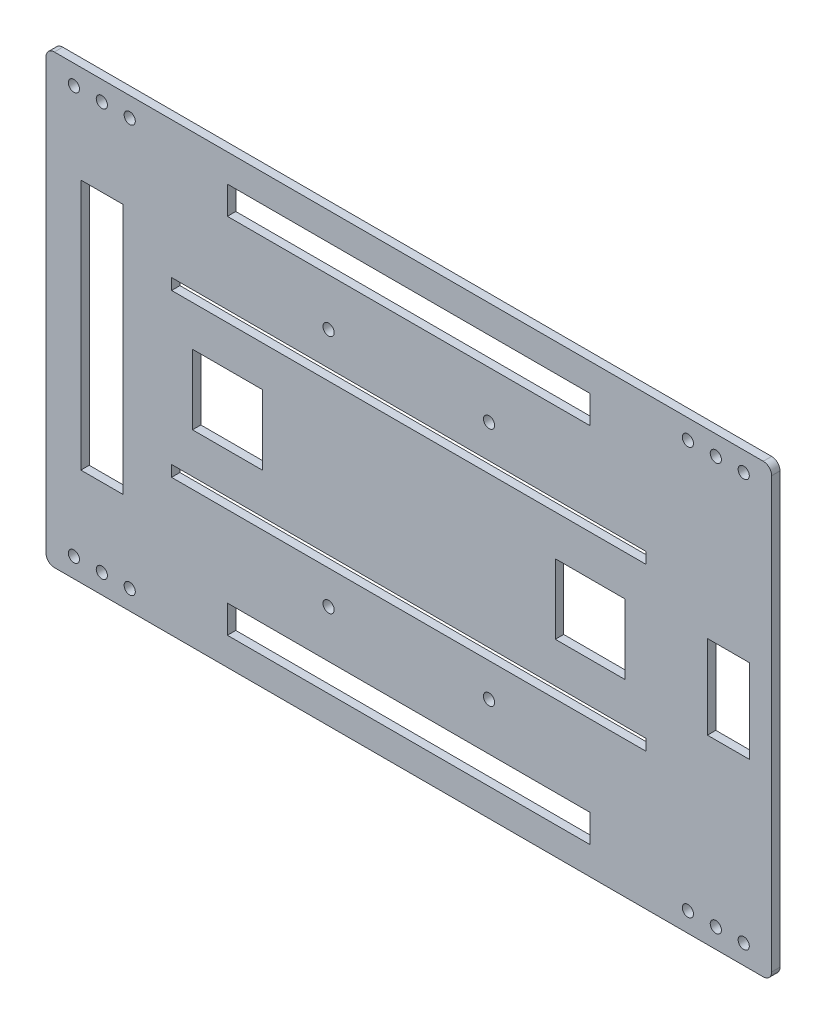
from build123d import *

# Parameters (mm, degrees)
MODEL_R             = 2
MODEL_W             = 130
MODEL_H             = 10
MODEL_W_2           = 15
MODEL_H_2           = 90
MODEL_W_3           = 25
MODEL_H_3           = 25
MODEL_H_4           = 30
MODEL_W_4           = 170
MODEL_H_5           = 4
EXTRUDE_1_DEPTH     = 3
SKETCH_1_R          = 2
CUT_EXTRUDE_1_DEPTH = 10


with BuildPart() as part:
    # Model → 凸台-拉伸1 (new body)
    with BuildSketch(Plane.XY):
        with BuildLine():
            Line((130, -77), (130, 77))
            ThreePointArc((130, 77), (129.121320344, 79.121320344), (127, 80))
            Line((127, 80), (-127, 80))
            ThreePointArc((-127, 80), (-129.121320344, 79.121320344), (-130, 77))
            Line((-130, 77), (-130, -77))
            ThreePointArc((-130, -77), (-129.121320344, -79.121320344), (-127, -80))
            Line((-127, -80), (127, -80))
            ThreePointArc((127, -80), (129.121320344, -79.121320344), (130, -77))
        make_face()
        with Locations((-110, 73)):
            Circle(MODEL_R, mode=Mode.SUBTRACT)
        with Locations((110, 73)):
            Circle(MODEL_R, mode=Mode.SUBTRACT)
        with Locations((110, -73)):
            Circle(MODEL_R, mode=Mode.SUBTRACT)
        with Locations((-110, -73)):
            Circle(MODEL_R, mode=Mode.SUBTRACT)
        with Locations((-120, 73)):
            Circle(MODEL_R, mode=Mode.SUBTRACT)
        with Locations((120, 73)):
            Circle(MODEL_R, mode=Mode.SUBTRACT)
        with Locations((-120, -73)):
            Circle(MODEL_R, mode=Mode.SUBTRACT)
        with Locations((120, -73)):
            Circle(MODEL_R, mode=Mode.SUBTRACT)
        with Locations((-100, 73)):
            Circle(MODEL_R, mode=Mode.SUBTRACT)
        with Locations((100, 73)):
            Circle(MODEL_R, mode=Mode.SUBTRACT)
        with Locations((-100, -73)):
            Circle(MODEL_R, mode=Mode.SUBTRACT)
        with Locations((100, -73)):
            Circle(MODEL_R, mode=Mode.SUBTRACT)
        with Locations((0, 65)):
            Rectangle(MODEL_W, MODEL_H, mode=Mode.SUBTRACT)
        with Locations((0, -65)):
            Rectangle(MODEL_W, MODEL_H, mode=Mode.SUBTRACT)
        with Locations((-110, 0)):
            Rectangle(MODEL_W_2, MODEL_H_2, mode=Mode.SUBTRACT)
        with Locations((65, 0)):
            Rectangle(MODEL_W_3, MODEL_H_3, mode=Mode.SUBTRACT)
        with Locations((-65, 0)):
            Rectangle(MODEL_W_3, MODEL_H_3, mode=Mode.SUBTRACT)
        with Locations((114.5, 0)):
            Rectangle(MODEL_W_2, MODEL_H_4, mode=Mode.SUBTRACT)
        with Locations((0, 29)):
            Rectangle(MODEL_W_4, MODEL_H_5, mode=Mode.SUBTRACT)
        with Locations((0, -29)):
            Rectangle(MODEL_W_4, MODEL_H_5, mode=Mode.SUBTRACT)
    extrude(amount=EXTRUDE_1_DEPTH)

    # 草图1 → 切除-拉伸1 (cut)
    with BuildSketch(Plane.XY.offset(3)):
        with Locations((-28.75, 43)):
            Circle(SKETCH_1_R)
        with Locations((28.75, 43)):
            Circle(SKETCH_1_R)
        with Locations((-28.75, -43)):
            Circle(SKETCH_1_R)
        with Locations((28.75, -43)):
            Circle(SKETCH_1_R)
    extrude(amount=-CUT_EXTRUDE_1_DEPTH, mode=Mode.SUBTRACT)


solid = part.part
